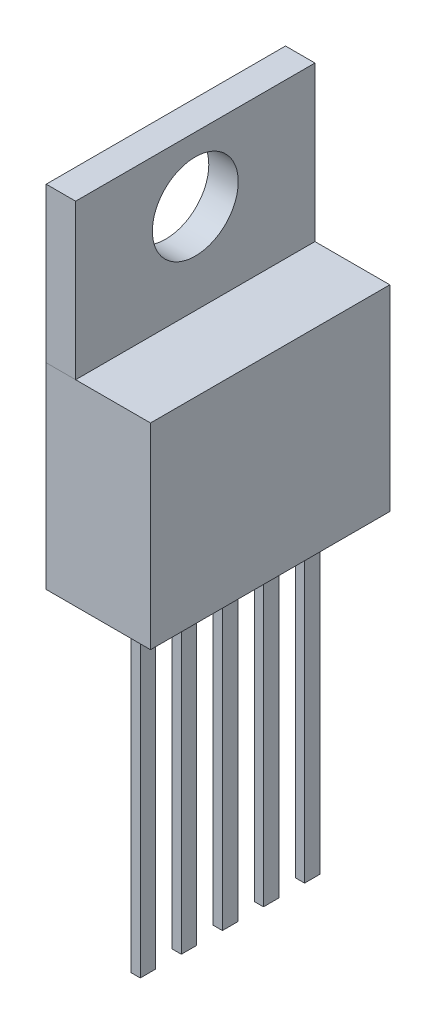
from build123d import *

# Parameters (mm, degrees)
SKETCH1_W           = 9.906
SKETCH1_H           = 8.128
BOSS_EXTRUDE1_DEPTH = 4.318
SKETCH2_W           = 9.906
SKETCH2_H           = 6.401
SKETCH2_R           = 1.778
BOSS_EXTRUDE3_DEPTH = 1.219
BOSS_EXTRUDE4_DEPTH = 13.284


with BuildPart() as part:
    # Sketch1 → Boss-Extrude1 (new body)
    with BuildSketch(Plane(origin=(0, 0, 0), x_dir=(0, 0, -1), z_dir=(1, 0, 0))):
        Rectangle(SKETCH1_W, SKETCH1_H)
    extrude(amount=BOSS_EXTRUDE1_DEPTH)

    # Sketch2 → Boss-Extrude3 (add)
    with BuildSketch(Plane(origin=(0, 0, 0), x_dir=(0, 0, -1), z_dir=(1, 0, 0))):
        with Locations((0, 7.2645)):
            Rectangle(SKETCH2_W, SKETCH2_H)
        with Locations((0, 7.798)):
            Circle(SKETCH2_R, mode=Mode.SUBTRACT)
    extrude(amount=BOSS_EXTRUDE3_DEPTH)

    # Sketch3 → Boss-Extrude4 (add)
    with BuildSketch(Plane(origin=(0, -4.064, 0), x_dir=(-1, 0, 0), z_dir=(0, -1, 0))):
        Polygon((-2.591, -1.949316438), (-2.591, -1.314316438), (-2.21, -1.314316438), (-2.21, -1.631816438), (-2.21, -1.949316438), align=None)
        Polygon((-2.21, 0.068183562), (-2.21, -0.249316438), (-2.591, -0.249316438), (-2.591, 0.385683562), (-2.21, 0.385683562), align=None)
        Polygon((-2.591, -3.649316438), (-2.591, -3.014316438), (-2.21, -3.014316438), (-2.21, -3.331816438), (-2.21, -3.649316438), align=None)
        Polygon((-2.591, 1.450683562), (-2.591, 2.085683562), (-2.21, 2.085683562), (-2.21, 1.768183562), (-2.21, 1.450683562), align=None)
        Polygon((-2.591, 3.150683562), (-2.591, 3.785683562), (-2.21, 3.785683562), (-2.21, 3.468183562), (-2.21, 3.150683562), align=None)
    extrude(amount=BOSS_EXTRUDE4_DEPTH)


solid = part.part
